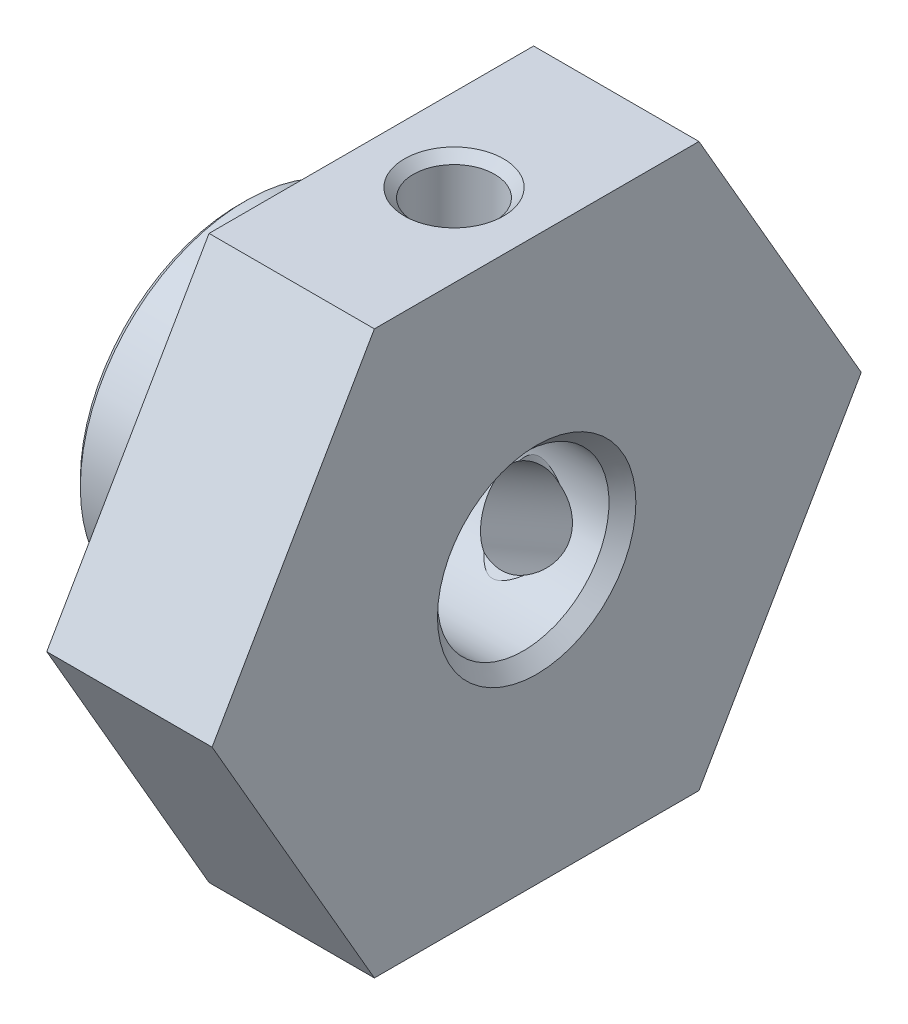
from build123d import *

# Parameters (mm, degrees)
SKETCH3_W          = 34
SKETCH3_H          = 34
CUT_EXTRUDE1_DEPTH = 9


with BuildPart() as part:
    # Sketch1 → Revolve1 (revolve)
    with BuildSketch(Plane.XY):
        Polygon((0, 0), (0, 4.8), (0.2, 5), (4, 5), (4, 10.2), (9, 10.2), (9, 0), align=None)
    revolve(axis=Axis((9, 0, 0), (-1, 0, 0)))

    # Sketch2 → Cut-Revolve1 (revolve, cut)
    with BuildSketch(Plane.XY):
        Polygon((0, 0), (0, 3), (0.406, 2.594), (8.594, 2.594), (9, 3), (9, 0), align=None)
    revolve(axis=Axis((9, 0, 0), (-1, 0, 0)), mode=Mode.SUBTRACT)

    # Sketch3 → Cut-Extrude1 (cut)
    with BuildSketch(Plane(origin=(0, 0, 0), x_dir=(0, 0, -1), z_dir=(1, 0, 0))):
        Rectangle(SKETCH3_W, SKETCH3_H)
        Polygon((-9.814954576, 0), (-4.907477288, -8.5), (4.907477288, -8.5), (9.814954576, 0), (4.907477288, 8.5), (-4.907477288, 8.5), align=None, mode=Mode.SUBTRACT)
    extrude(amount=CUT_EXTRUDE1_DEPTH, mode=Mode.SUBTRACT)

    # Sketch4 → Cut-Revolve2 (revolve, cut)
    with BuildSketch(Plane(origin=(6.5, 0, 0), x_dir=(0, 0, -1), z_dir=(1, 0, 0))):
        Polygon((0, 8.5), (1.5, 8.5), (1.2295, 8.2295), (1.2295, 2.3645), (1.5, 2.094), (0, 2.094), align=None)
    revolve(axis=Axis((6.5, 2.094, 0), (0, 1, 0)), mode=Mode.SUBTRACT)

    # Sketch5 → Cut-Revolve3 (revolve, cut)
    with BuildSketch(Plane(origin=(6.5, 0, 0), x_dir=(0, 0, -1), z_dir=(1, 0, 0))):
        Polygon((7.361215932, -4.25), (6.611215932, -5.549038106), (6.51220606, -5.179528234), (1.432967067, -2.247028234), (1.063457196, -2.346038106), (1.813457196, -1.047), align=None)
    revolve(axis=Axis((6.5, -1.047, -1.813457196), (0, -0.5, -0.866025404)), mode=Mode.SUBTRACT)


solid = part.part
